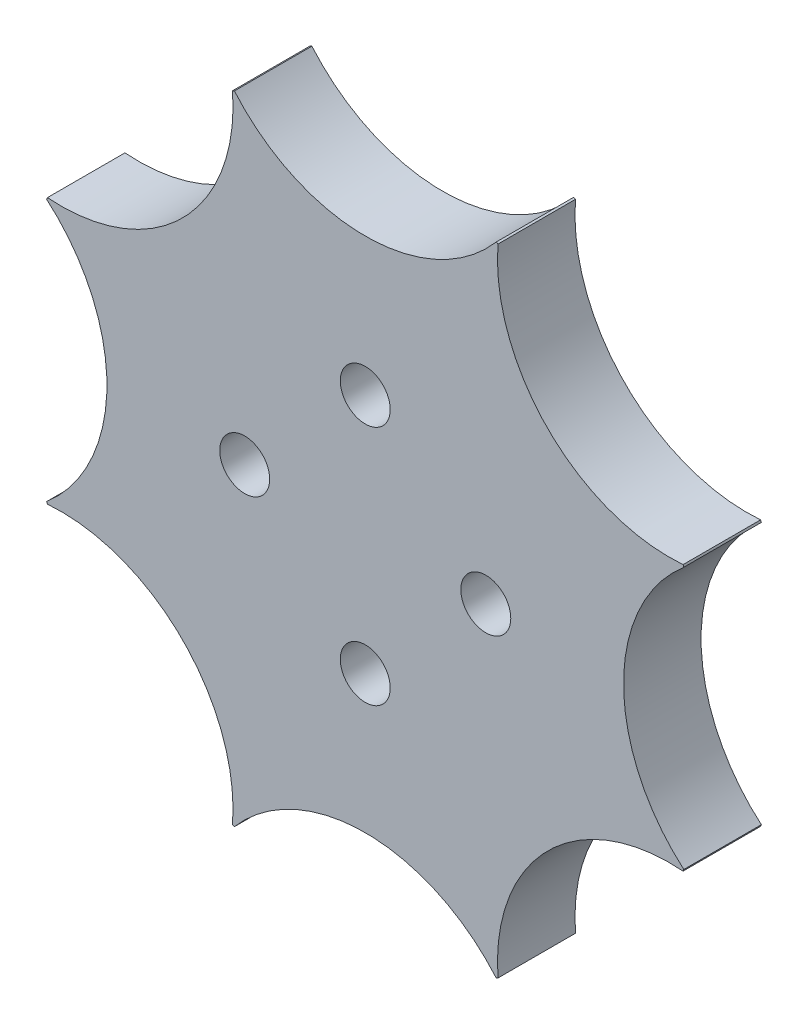
from build123d import *

# Parameters (mm, degrees)
BOSS_EXTRUDE1_DEPTH = 4.5
SKETCH3_R           = 10.5
CUT_EXTRUDE1_DEPTH  = 2
CUT_EXTRUDE2_REACH  = 6.5
SKETCH4_R           = 1.45


with BuildPart() as part:
    # Sketch2 → Boss-Extrude1 (new body)
    with BuildSketch(Plane.XY):
        with BuildLine():
            ThreePointArc((18.5, -7.599342077), (15, 0), (18.5, 7.599342077))
            ThreePointArc((18.5, 7.599342077), (18.47759065, 7.653668647), (18.455021767, 7.707929137))
            ThreePointArc((18.455021767, 7.707929137), (10.606601718, 10.606601718), (7.707929137, 18.455021767))
            ThreePointArc((7.707929137, 18.455021767), (7.653668647, 18.47759065), (7.599342077, 18.5))
            ThreePointArc((7.599342077, 18.5), (0, 15), (-7.599342077, 18.5))
            ThreePointArc((-7.599342077, 18.5), (-7.653668647, 18.47759065), (-7.707929137, 18.455021767))
            ThreePointArc((-7.707929137, 18.455021767), (-7.685237295, 18.066640012), (-7.67766953, 17.67766953))
            ThreePointArc((-7.67766953, 17.67766953), (-10.886996602, 10.33690927), (-18.455021767, 7.707929137))
            ThreePointArc((-18.455021767, 7.707929137), (-18.47759065, 7.653668647), (-18.5, 7.599342077))
            ThreePointArc((-18.5, 7.599342077), (-15.917048938, 4.183300133), (-15, 0))
            ThreePointArc((-15, 0), (-15.917048938, -4.183300133), (-18.5, -7.599342077))
            ThreePointArc((-18.5, -7.599342077), (-18.47759065, -7.653668647), (-18.455021767, -7.707929137))
            ThreePointArc((-18.455021767, -7.707929137), (-10.886996602, -10.33690927), (-7.67766953, -17.67766953))
            ThreePointArc((-7.67766953, -17.67766953), (-7.685237295, -18.066640012), (-7.707929137, -18.455021767))
            ThreePointArc((-7.707929137, -18.455021767), (-7.653668647, -18.47759065), (-7.599342077, -18.5))
            ThreePointArc((-7.599342077, -18.5), (0, -15), (7.599342077, -18.5))
            ThreePointArc((7.599342077, -18.5), (7.653668647, -18.47759065), (7.707929137, -18.455021767))
            ThreePointArc((7.707929137, -18.455021767), (10.606601718, -10.606601718), (18.455021767, -7.707929137))
            ThreePointArc((18.455021767, -7.707929137), (18.47759065, -7.653668647), (18.5, -7.599342077))
        make_face()
    extrude(amount=BOSS_EXTRUDE1_DEPTH)

    # Sketch3 → Cut-Extrude1 (cut)
    with BuildSketch(Plane.XY):
        Circle(SKETCH3_R)
    extrude(amount=CUT_EXTRUDE1_DEPTH, mode=Mode.SUBTRACT)

    # Sketch4 → Cut-Extrude2 (cut, up to next)
    with BuildSketch(Plane.XY.offset(4.5), mode=Mode.PRIVATE) as cut_extrude2_sk1:
        with Locations((0, 7)):
            Circle(SKETCH4_R)
    cut_extrude2_tool1 = extrude(cut_extrude2_sk1.sketch, amount=-CUT_EXTRUDE2_REACH, mode=Mode.PRIVATE) & part.part
    add(cut_extrude2_tool1.solids().sort_by_distance((0, 7, 4.5))[0], mode=Mode.SUBTRACT)
    # Sketch4 → Cut-Extrude2 (cut, up to next)
    with BuildSketch(Plane.XY.offset(4.5), mode=Mode.PRIVATE) as cut_extrude2_sk2:
        with Locations((7, 0)):
            Circle(SKETCH4_R)
    cut_extrude2_tool2 = extrude(cut_extrude2_sk2.sketch, amount=-CUT_EXTRUDE2_REACH, mode=Mode.PRIVATE) & part.part
    add(cut_extrude2_tool2.solids().sort_by_distance((7, 0, 4.5))[0], mode=Mode.SUBTRACT)
    # Sketch4 → Cut-Extrude2 (cut, up to next)
    with BuildSketch(Plane.XY.offset(4.5), mode=Mode.PRIVATE) as cut_extrude2_sk3:
        with Locations((0, -7)):
            Circle(SKETCH4_R)
    cut_extrude2_tool3 = extrude(cut_extrude2_sk3.sketch, amount=-CUT_EXTRUDE2_REACH, mode=Mode.PRIVATE) & part.part
    add(cut_extrude2_tool3.solids().sort_by_distance((0, -7, 4.5))[0], mode=Mode.SUBTRACT)
    # Sketch4 → Cut-Extrude2 (cut, up to next)
    with BuildSketch(Plane.XY.offset(4.5), mode=Mode.PRIVATE) as cut_extrude2_sk4:
        with Locations((-7, 0)):
            Circle(SKETCH4_R)
    cut_extrude2_tool4 = extrude(cut_extrude2_sk4.sketch, amount=-CUT_EXTRUDE2_REACH, mode=Mode.PRIVATE) & part.part
    add(cut_extrude2_tool4.solids().sort_by_distance((-7, 0, 4.5))[0], mode=Mode.SUBTRACT)


solid = part.part
